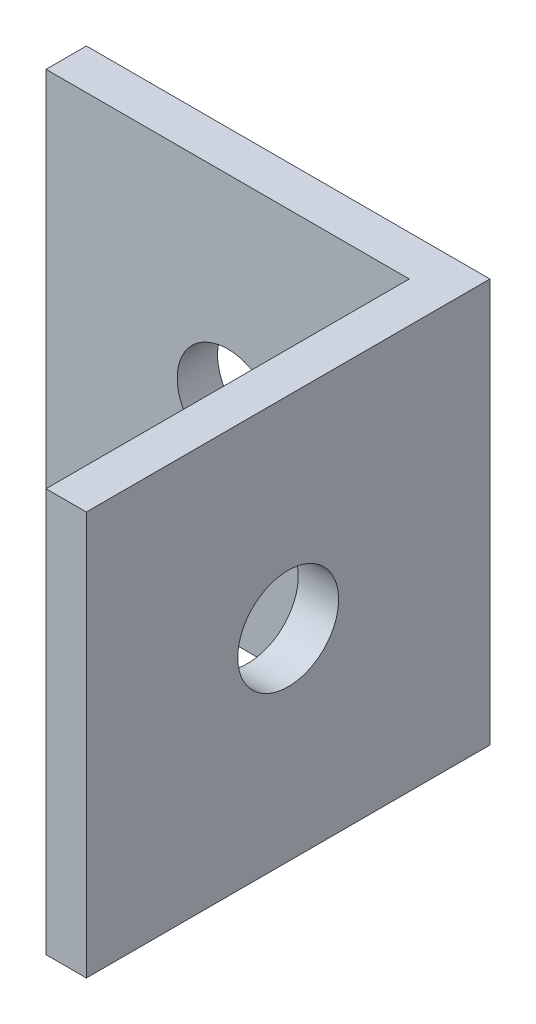
from build123d import *

# Parameters (mm, degrees)
SKETCH1_W           = 25.4
SKETCH1_H           = 25.4
BOSS_EXTRUDE1_DEPTH = 2.54
SKETCH2_W           = 25.4
SKETCH2_H           = 25.4
BOSS_EXTRUDE2_DEPTH = 2.54
SKETCH3_R           = 3.175
CUT_EXTRUDE1_DEPTH  = 2.54
SKETCH4_R           = 3.175
CUT_EXTRUDE2_DEPTH  = 2.54


with BuildPart() as part:
    # Sketch1 → Boss-Extrude1 (new body)
    with BuildSketch(Plane.XY):
        with Locations((12.7, 12.7)):
            Rectangle(SKETCH1_W, SKETCH1_H)
    extrude(amount=BOSS_EXTRUDE1_DEPTH)

    # Sketch2 → Boss-Extrude2 (add)
    with BuildSketch(Plane(origin=(25.4, 0, 0), x_dir=(0, 0, -1), z_dir=(1, 0, 0))):
        with Locations((-12.7, 12.7)):
            Rectangle(SKETCH2_W, SKETCH2_H)
    extrude(amount=-BOSS_EXTRUDE2_DEPTH)

    # Sketch3 → Cut-Extrude1 (cut)
    with BuildSketch(Plane.XY.offset(2.54)):
        with Locations((11.43, 12.7)):
            Circle(SKETCH3_R)
    extrude(amount=-CUT_EXTRUDE1_DEPTH, mode=Mode.SUBTRACT)

    # Sketch4 → Cut-Extrude2 (cut)
    with BuildSketch(Plane.ZY.offset(-22.86)):
        with Locations((12.7, 12.7)):
            Circle(SKETCH4_R)
    extrude(amount=-CUT_EXTRUDE2_DEPTH, mode=Mode.SUBTRACT)


solid = part.part
